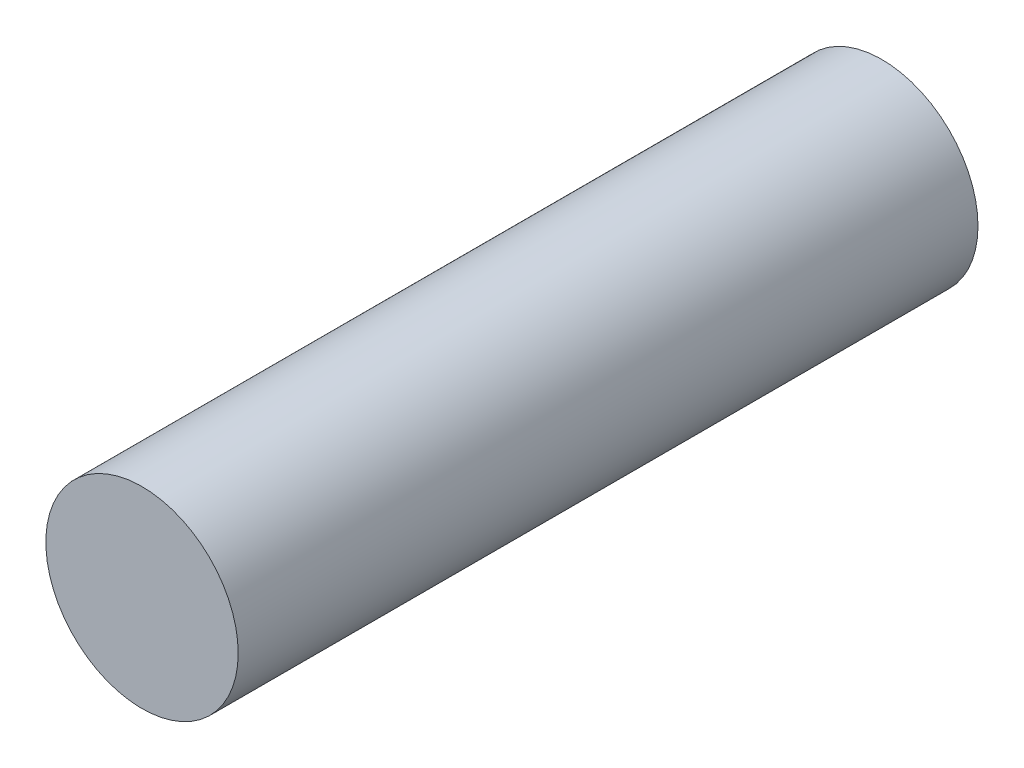
from build123d import *

# Parameters (mm, degrees)
SKETCH1_R      = 0.65
EXTRUDE1_DEPTH = 5


with BuildPart() as part:
    # Sketch1 → Extrude1 (new body)
    with BuildSketch(Plane.XY):
        Circle(SKETCH1_R)
    extrude(amount=EXTRUDE1_DEPTH)


solid = part.part
